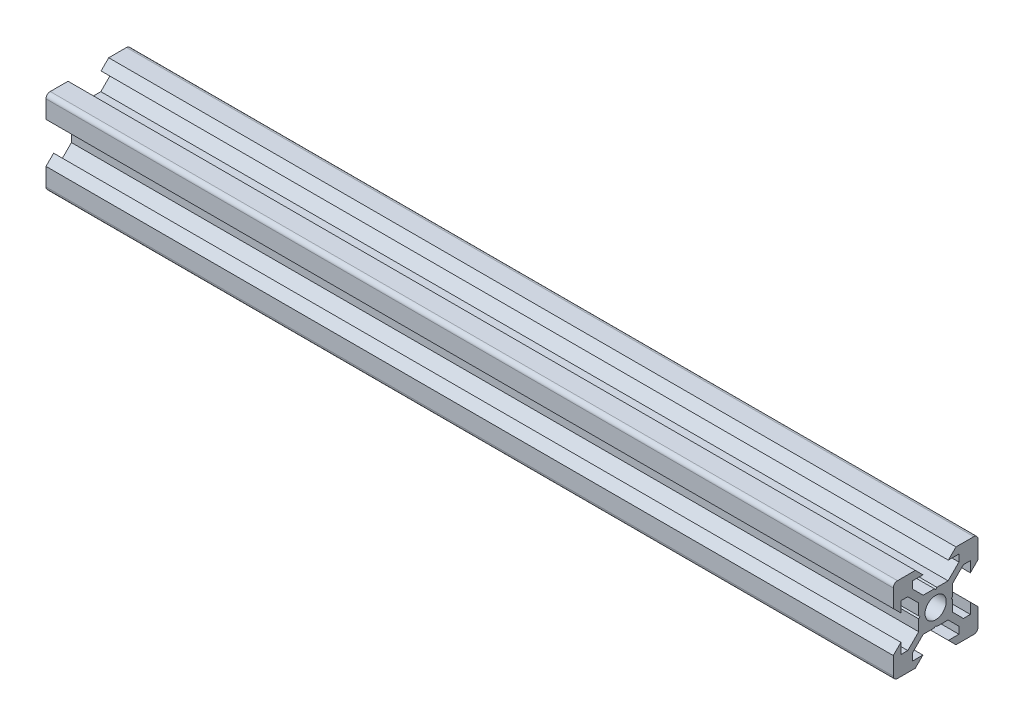
from build123d import *

# Parameters (mm, degrees)
SKETCH11_R                                  = 2.5
QUADRADO_PF20_11_PERFIL_2020_V_SLOT_1_DEPTH = 200


with BuildPart() as part:
    # Sketch11 → Quadrado PF20-11 - PERFIL 2020 V-SLOT(1) (new body)
    with BuildSketch(Plane.YZ):
        with BuildLine():
            Line((-4.8, 10), (-3, 8.2))
            Line((-3, 8.2), (-5.5, 8.2))
            Line((-5.5, 8.2), (-5.5, 6.560660172))
            Line((-5.5, 6.560660172), (-2.939339828, 4))
            Line((-2.939339828, 4), (-0.3, 4))
            Line((-0.3, 4), (0, 3.7))
            Line((0, 3.7), (0.3, 4))
            Line((0.3, 4), (2.939339828, 4))
            Line((2.939339828, 4), (5.5, 6.560660172))
            Line((5.5, 6.560660172), (5.5, 8.2))
            Line((5.5, 8.2), (3, 8.2))
            Line((3, 8.2), (4.8, 10))
            Line((4.8, 10), (9, 10))
            ThreePointArc((9, 10), (9.707106781, 9.707106781), (10, 9))
            Line((10, 9), (10, 4.8))
            Line((10, 4.8), (8.2, 3))
            Line((8.2, 3), (8.2, 5.5))
            Line((8.2, 5.5), (6.560660172, 5.5))
            Line((6.560660172, 5.5), (4, 2.939339828))
            Line((4, 2.939339828), (4, 0.3))
            Line((4, 0.3), (3.7, 0))
            Line((3.7, 0), (4, -0.3))
            Line((4, -0.3), (4, -2.939339828))
            Line((4, -2.939339828), (6.560660172, -5.5))
            Line((6.560660172, -5.5), (8.2, -5.5))
            Line((8.2, -5.5), (8.2, -3))
            Line((8.2, -3), (10, -4.8))
            Line((10, -4.8), (10, -9))
            ThreePointArc((10, -9), (9.707106781, -9.707106781), (9, -10))
            Line((9, -10), (4.8, -10))
            Line((4.8, -10), (3, -8.2))
            Line((3, -8.2), (5.5, -8.2))
            Line((5.5, -8.2), (5.5, -6.560660172))
            Line((5.5, -6.560660172), (2.939339828, -4))
            Line((2.939339828, -4), (0.3, -4))
            Line((0.3, -4), (0, -3.7))
            Line((0, -3.7), (-0.3, -4))
            Line((-0.3, -4), (-2.939339828, -4))
            Line((-2.939339828, -4), (-5.5, -6.560660172))
            Line((-5.5, -6.560660172), (-5.5, -8.2))
            Line((-5.5, -8.2), (-3, -8.2))
            Line((-3, -8.2), (-4.8, -10))
            Line((-4.8, -10), (-9, -10))
            ThreePointArc((-9, -10), (-9.707106781, -9.707106781), (-10, -9))
            Line((-10, -9), (-10, -4.8))
            Line((-10, -4.8), (-8.2, -3))
            Line((-8.2, -3), (-8.2, -5.5))
            Line((-8.2, -5.5), (-6.560660172, -5.5))
            Line((-6.560660172, -5.5), (-4, -2.939339828))
            Line((-4, -2.939339828), (-4, -0.3))
            Line((-4, -0.3), (-3.7, 0))
            Line((-3.7, 0), (-4, 0.3))
            Line((-4, 0.3), (-4, 2.939339828))
            Line((-4, 2.939339828), (-6.560660172, 5.5))
            Line((-6.560660172, 5.5), (-8.2, 5.5))
            Line((-8.2, 5.5), (-8.2, 3))
            Line((-8.2, 3), (-10, 4.8))
            Line((-10, 4.8), (-10, 9))
            ThreePointArc((-10, 9), (-9.707106781, 9.707106781), (-9, 10))
            Line((-9, 10), (-4.8, 10))
        make_face()
        Circle(SKETCH11_R, mode=Mode.SUBTRACT)
    extrude(amount=QUADRADO_PF20_11_PERFIL_2020_V_SLOT_1_DEPTH)


solid = part.part
